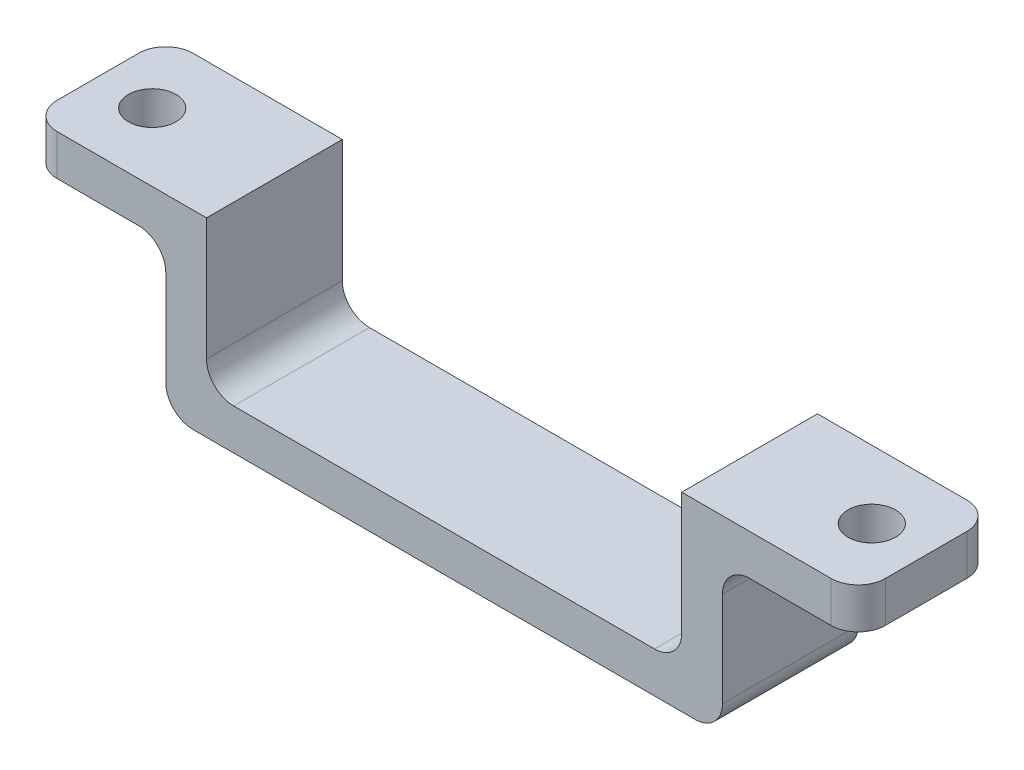
from build123d import *

# Parameters (mm, degrees)
EXTRUDE_THIN1_DEPTH = 5
FILLET1_R           = 2
FILLET2_R           = 2
SKETCH2_R           = 1.75
CUT_EXTRUDE1_DEPTH  = 4


with BuildPart() as part:
    # Sketch1 → Extrude-Thin1 (new body, symmetric)
    with BuildSketch(Plane.XY):
        Polygon((-30.5, 0), (-17.5, 0), (-17.5, -11), (17.5, -11), (17.5, 0), (30.5, 0), (30.5, -3), (20.5, -3), (20.5, -14), (-20.5, -14), (-20.5, -3), (-30.5, -3), align=None)
    extrude(amount=EXTRUDE_THIN1_DEPTH, both=True)

    # Fillet1
    fillet1_edges = [part.edges().sort_by_distance(p)[0] for p in [
        (20.5, -3, 0),
        (20.5, -14, 0),
        (-20.5, -14, 0),
        (-20.5, -3, 0),
        (-17.5, -11, 0),
        (17.5, -11, 0),
    ]]
    fillet(fillet1_edges, radius=FILLET1_R)

    # Fillet2
    fillet2_edges = [part.edges().sort_by_distance(p)[0] for p in [
        (-30.5, -1.5, -5),
        (30.5, -1.5, -5),
        (-30.5, -1.5, 5),
        (30.5, -1.5, 5),
    ]]
    fillet(fillet2_edges, radius=FILLET2_R)

    # Sketch2 → Cut-Extrude1 (cut, through all)
    with BuildSketch(Plane(origin=(0, -3, 0), x_dir=(-1, 0, 0), z_dir=(0, -1, 0))):
        with Locations((-26.5, 0)):
            Circle(SKETCH2_R)
        with Locations((26.5, 0)):
            Circle(SKETCH2_R)
    extrude(amount=-CUT_EXTRUDE1_DEPTH, mode=Mode.SUBTRACT)


solid = part.part
